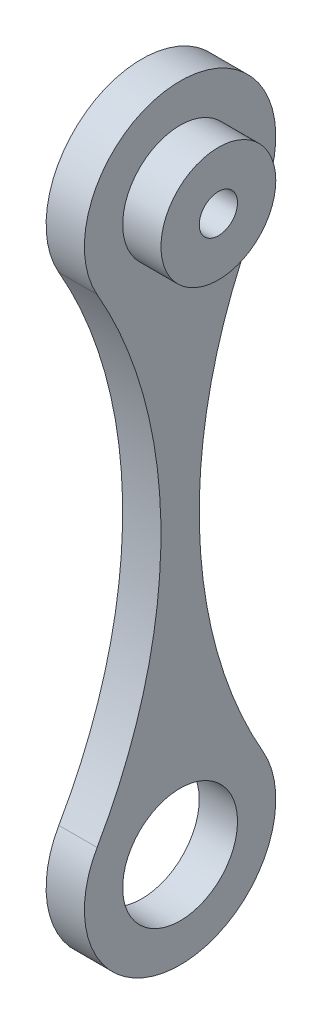
from build123d import *

# Parameters (mm, degrees)
SKETCH1_R           = 15
BOSS_EXTRUDE1_DEPTH = 10
SKETCH2_R           = 15
BOSS_EXTRUDE2_DEPTH = 10
SKETCH3_R           = 5
CUT_EXTRUDE1_DEPTH  = 45


with BuildPart() as part:
    # Sketch1 → Boss-Extrude1 (new body)
    with BuildSketch(Plane(origin=(0, 0, 0), x_dir=(0, 0, -1), z_dir=(1, 0, 0))):
        with BuildLine():
            ThreePointArc((-21.680497925, -12.44813278), (-5, -75), (-21.680497925, -137.55186722))
            ThreePointArc((-21.680497925, -137.55186722), (0, -175), (21.680497925, -137.55186722))
            ThreePointArc((21.680497925, -137.55186722), (5, -75), (21.680497925, -12.44813278))
            ThreePointArc((21.680497925, -12.44813278), (0, 25), (-21.680497925, -12.44813278))
        make_face()
        with Locations((0, -150)):
            Circle(SKETCH1_R, mode=Mode.SUBTRACT)
    extrude(amount=BOSS_EXTRUDE1_DEPTH)

    # Sketch2 → Boss-Extrude2 (add)
    with BuildSketch(Plane(origin=(10, 0, 0), x_dir=(0, 0, -1), z_dir=(1, 0, 0))):
        Circle(SKETCH2_R)
    extrude(amount=BOSS_EXTRUDE2_DEPTH)

    # Sketch3 → Cut-Extrude1 (cut)
    with BuildSketch(Plane(origin=(20, 0, 0), x_dir=(0, 0, -1), z_dir=(1, 0, 0))):
        Circle(SKETCH3_R)
    extrude(amount=-CUT_EXTRUDE1_DEPTH, mode=Mode.SUBTRACT)


solid = part.part
